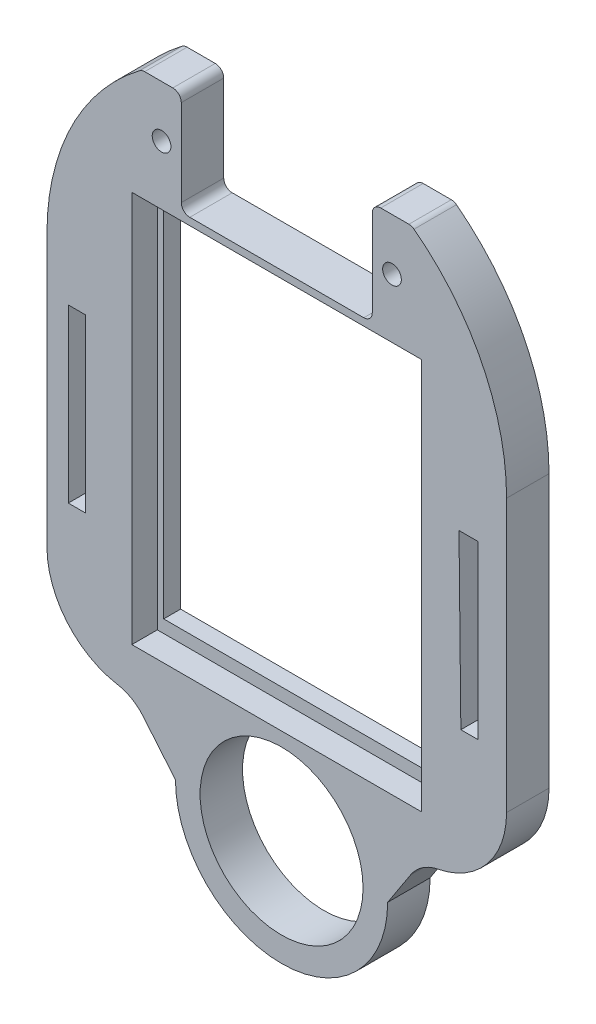
from build123d import *

# Parameters (mm, degrees)
ESQUISSE1_W             = 31.7
ESQUISSE1_H             = 43.35
BOSS_EXTRU_1_DEPTH      = 2
ESQUISSE2_W             = 54.15
ESQUISSE2_H             = 52.075
ESQUISSE2_W_2           = 34.15
ESQUISSE2_H_2           = 46.15
BOSS_EXTRU_2_DEPTH      = 3
ENL_V_MAT_EXTRU_1_DEPTH = 44.310222651
CONG_1_R                = 10
BOSS_EXTRU_3_START      = 5
ESQUISSE4_R             = 1.1
ESQUISSE4_W             = 2
ESQUISSE4_H             = 20.22
ESQUISSE4_W_2           = 2.219999677
ESQUISSE4_H_2           = 20.218803133
BOSS_EXTRU_3_DEPTH      = 5
CONG_2_R                = 1
CONG_3_R                = 5
ESQUISSE5_R             = 9.6
ENL_V_MAT_EXTRU_2_DEPTH = 56.978552241
ESQUISSE7_W             = 31.7
ESQUISSE7_H             = 43.35
ENL_V_MAT_EXTRU_3_DEPTH = 56.978552241
ESQUISSE7_4_W           = 34.15
ESQUISSE7_4_H           = 46.15
ENL_V_MAT_EXTRU_4_DEPTH = 3


with BuildPart() as part:
    # Esquisse1 → Boss.-Extru.1 (new body)
    with BuildSketch(Plane.XY):
        Polygon((-20.243056538, 24.478190482), (-20.243056538, -25.521809518), (-20.243056538, -25.596809518), (6.831943462, -25.596809518), (33.906943462, -25.596809518), (33.906943462, -25.521809518), (33.906943462, 24.478190482), (33.906943462, 26.478190482), (5.831943462, 26.478190482), (-20.243056538, 26.478190482), align=None)
        with Locations((6.356943462, -0.426809518)):
            Rectangle(ESQUISSE1_W, ESQUISSE1_H, mode=Mode.SUBTRACT)
    extrude(amount=BOSS_EXTRU_1_DEPTH)

    # Esquisse2 → Boss.-Extru.2 (add)
    with BuildSketch(Plane.XY.offset(2)):
        with Locations((6.831943462, 0.440690482)):
            Rectangle(ESQUISSE2_W, ESQUISSE2_H)
        with Locations((5.881943462, -0.331809518)):
            Rectangle(ESQUISSE2_W_2, ESQUISSE2_H_2, mode=Mode.SUBTRACT)
    extrude(amount=BOSS_EXTRU_2_DEPTH)

    # Esquisse3 → Enl_v. mat.-Extru.1 (cut, through all)
    with BuildSketch(Plane.XY.offset(5)):
        Polygon((-17.730491461, -9.839116901), (-17.730491461, 10.380883099), (-15.510491784, 10.379686232), (-15.730491461, -9.839116901), align=None)
        Polygon((28.519508539, -9.839116901), (28.299508862, 10.379686232), (30.519508539, 10.380883099), (30.519508539, -9.839116901), align=None)
    extrude(amount=-ENL_V_MAT_EXTRU_1_DEPTH, mode=Mode.SUBTRACT)

    # Cong_1
    cong_1_edges = [part.edges().sort_by_distance(p)[0] for p in [
        (33.906943462, 26.478190482, 2.5),
        (33.906943462, -25.596809518, 2.5),
        (-20.243056538, -25.596809518, 2.5),
        (-20.243056538, 26.478190482, 2.5),
    ]]
    fillet(cong_1_edges, radius=CONG_1_R)

    # Esquisse4 → Boss.-Extru.3 (add)
    with BuildSketch(Plane.XY.offset(BOSS_EXTRU_3_START)):
        with BuildLine():
            Line((-9.068056538, 38.678190482), (-4.418056538, 38.678190482))
            Line((-4.418056538, 38.678190482), (-4.418056538, 26.478190482))
            Line((-4.418056538, 26.478190482), (18.081943462, 26.478190482))
            Line((18.081943462, 26.478190482), (18.081943462, 38.678190482))
            Line((18.081943462, 38.678190482), (22.731943462, 38.678190482))
            ThreePointArc((22.731943462, 38.678190482), (30.955617573, 28.905183532), (33.906943462, 16.478190482))
            Line((33.906943462, 16.478190482), (33.906943462, -15.596809518))
            ThreePointArc((33.906943462, -15.596809518), (30.978011273, -22.66787733), (23.906943462, -25.596809518))
            Line((23.906943462, -25.596809518), (19.895450173, -31.759659919))
            ThreePointArc((19.895450173, -31.759659919), (7.395450173, -44.259659919), (-5.104549827, -31.759659919))
            Line((-5.104549827, -31.759659919), (-10.243056538, -25.596809518))
            ThreePointArc((-10.243056538, -25.596809518), (-17.31412435, -22.66787733), (-20.243056538, -15.596809518))
            Line((-20.243056538, -15.596809518), (-20.243056538, 16.478190482))
            ThreePointArc((-20.243056538, 16.478190482), (-17.29173065, 28.905183532), (-9.068056538, 38.678190482))
        make_face()
        with Locations((-6.743056538, 32.578190482)):
            Circle(ESQUISSE4_R, mode=Mode.SUBTRACT)
        with Locations((20.406943462, 32.578190482)):
            Circle(ESQUISSE4_R, mode=Mode.SUBTRACT)
        with Locations((-16.730491461, 0.270883099)):
            Rectangle(ESQUISSE4_W, ESQUISSE4_H, mode=Mode.SUBTRACT)
        with Locations((29.409508701, 0.270284666)):
            Rectangle(ESQUISSE4_W_2, ESQUISSE4_H_2, mode=Mode.SUBTRACT)
    extrude(amount=-BOSS_EXTRU_3_DEPTH)

    # Cong_2
    cong_2_edges = [part.edges().sort_by_distance(p)[0] for p in [
        (-4.418056538, 26.478190482, 2.5),
        (18.081943462, 38.678190482, 2.5),
        (-4.418056538, 38.678190482, 2.5),
        (18.081943462, 26.478190482, 2.5),
        (22.731943462, 38.678190482, 2.5),
        (-9.068056538, 38.678190482, 2.5),
    ]]
    fillet(cong_2_edges, radius=CONG_2_R)

    # Cong_3
    cong_3_edges = [part.edges().sort_by_distance(p)[0] for p in [
        (-10.243056538, -25.596809518, 2.5),
        (23.906943462, -25.596809518, 2.5),
    ]]
    fillet(cong_3_edges, radius=CONG_3_R)

    # Esquisse5 → Enl_v. mat.-Extru.2 (cut, through all)
    with BuildSketch(Plane.XY.offset(5)):
        with Locations((7.395450173, -31.759659919)):
            Circle(ESQUISSE5_R)
    extrude(amount=-ENL_V_MAT_EXTRU_2_DEPTH, mode=Mode.SUBTRACT)

    # Esquisse7 → Enl_v. mat.-Extru.3 (cut, through all)
    with BuildSketch(Plane.XY.offset(5)):
        with Locations((6.356943462, 2.63695892)):
            Rectangle(ESQUISSE7_W, ESQUISSE7_H)
    extrude(amount=-ENL_V_MAT_EXTRU_3_DEPTH, mode=Mode.SUBTRACT)

    # Esquisse7_4 → Enl_v. mat.-Extru.4 (cut)
    with BuildSketch(Plane.XY.offset(5)):
        with Locations((6.831943462, 2.54195892)):
            Rectangle(ESQUISSE7_4_W, ESQUISSE7_4_H)
    extrude(amount=-ENL_V_MAT_EXTRU_4_DEPTH, mode=Mode.SUBTRACT)


solid = part.part
